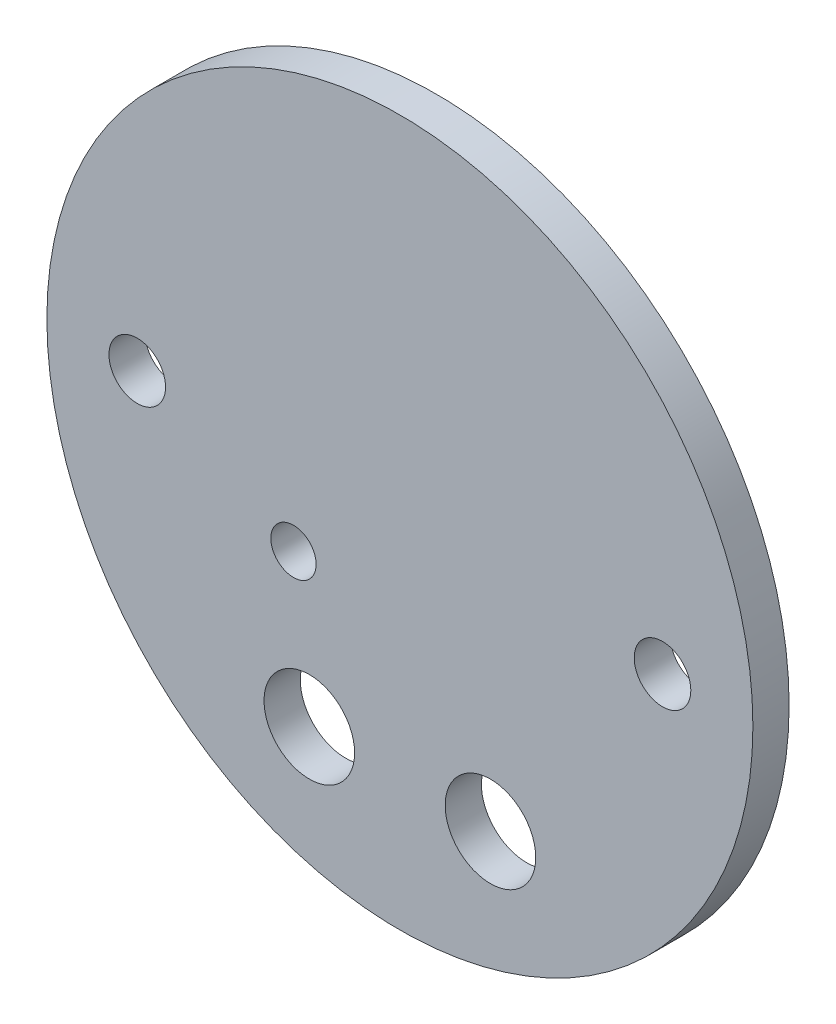
from build123d import *

# Parameters (mm, degrees)
SKETCH1_R           = 49.5046
BOSS_EXTRUDE1_DEPTH = 5.08
SKETCH2_R           = 47.625
BOSS_EXTRUDE2_DEPTH = 3.175
SKETCH3_R           = 6.35
SKETCH3_R_2         = 3.96875
SKETCH3_R_3         = 3.175
CUT_EXTRUDE1_DEPTH  = 9.255
SKETCH4_R           = 53.657769874
CUT_EXTRUDE2_DEPTH  = 3.175


with BuildPart() as part:
    # Sketch1 → Boss-Extrude1 (new body)
    with BuildSketch(Plane.XY):
        Circle(SKETCH1_R)
    extrude(amount=BOSS_EXTRUDE1_DEPTH)

    # Sketch2 → Boss-Extrude2 (add)
    with BuildSketch(Plane.XY.offset(5.08)):
        Circle(SKETCH2_R)
    extrude(amount=BOSS_EXTRUDE2_DEPTH)

    # Sketch3 → Cut-Extrude1 (cut, through all)
    with BuildSketch(Plane.XY.offset(8.255)):
        with Locations((-12.7, -31.166793627)):
            Circle(SKETCH3_R)
        with Locations((12.7, -31.166793627)):
            Circle(SKETCH3_R)
        with Locations((-36.83, 0)):
            Circle(SKETCH3_R_2)
        with Locations((36.83, 0)):
            Circle(SKETCH3_R_2)
        with Locations((-14.921345457, -10.968575281)):
            Circle(SKETCH3_R_3)
    extrude(amount=-CUT_EXTRUDE1_DEPTH, mode=Mode.SUBTRACT)

    # Sketch4 → Cut-Extrude2 (cut)
    with BuildSketch(Plane.XY.offset(8.255)):
        Circle(SKETCH4_R)
    extrude(amount=-CUT_EXTRUDE2_DEPTH, mode=Mode.SUBTRACT)


solid = part.part
